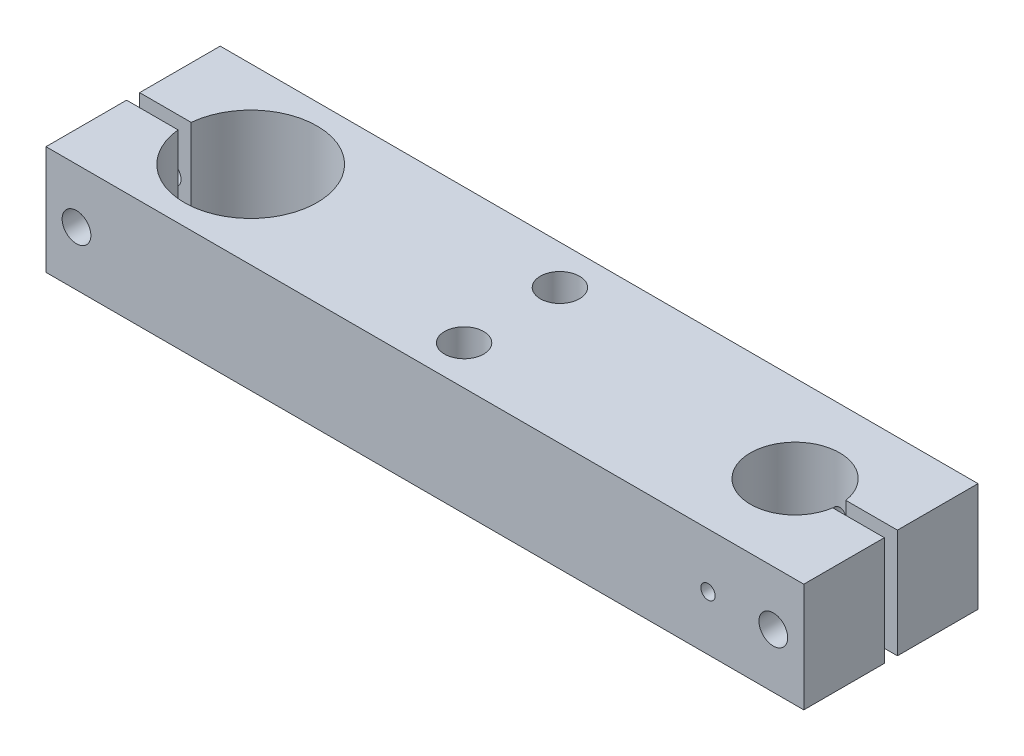
from build123d import *

# Parameters (mm, degrees)
BOSS_EXTRU_1_DEPTH   = 25
D_GAGEMENT_M61_D     = 6.6
D_GAGEMENT_M61_DEPTH = 18.5
TROU_TARAUD_M61_D    = 5
TROU_TARAUD_M41_D    = 3.3
D_GAGEMENT_M81_D     = 9


with BuildPart() as part:
    # Esquisse1 → Boss.-Extru.1 (new body)
    with BuildSketch(Plane(origin=(0, 0, 0), x_dir=(1, 0, 0), z_dir=(0, 1, 0))):
        with BuildLine():
            Line((-87, -1.5), (-87, -20))
            Line((-87, -20), (87, -20))
            Line((87, -20), (87, -1.5))
            Line((87, -1.5), (75.139649895, -1.5))
            ThreePointArc((75.139649895, -1.5), (54.75, 0), (75.139649895, 1.5))
            Line((75.139649895, 1.5), (87, 1.5))
            Line((87, 1.5), (87, 20))
            Line((87, 20), (-87, 20))
            Line((-87, 20), (-87, 1.5))
            Line((-87, 1.5), (-75.176050211, 1.5))
            ThreePointArc((-75.176050211, 1.5), (-59.249089125, 15.231501333), (-44.75, 0))
            ThreePointArc((-44.75, 0), (-59.249089125, -15.231501333), (-75.176050211, -1.5))
            Line((-75.176050211, -1.5), (-87, -1.5))
        make_face()
    extrude(amount=BOSS_EXTRU_1_DEPTH)

    # Dégagement M61
    with Locations(Plane(origin=(80, 12.5, 20), x_dir=(1, 0, 0), z_dir=(0, 0, 1))):
        with Locations((0, 0), (-160, 0)):
            Hole(D_GAGEMENT_M61_D / 2, depth=D_GAGEMENT_M61_DEPTH)

    # Trou taraudé M61 (through all)
    with Locations(Plane(origin=(80, 12.5, -1.5), x_dir=(1, 0, 0), z_dir=(0, 0, 1))):
        with Locations((0, 0), (-160, 0)):
            Hole(TROU_TARAUD_M61_D / 2)

    # Trou taraudé M41 (through all)
    with Locations(Plane(origin=(65, 12.5, 20), x_dir=(1, 0, 0), z_dir=(0, 0, 1))):
        with Locations((0, 0)):
            Hole(TROU_TARAUD_M41_D / 2)

    # Dégagement M81 (through all)
    with Locations(Plane(origin=(0, 25, -11), x_dir=(0, 0, 1), z_dir=(0, 1, 0))):
        with Locations((0, 0), (22, 0)):
            Hole(D_GAGEMENT_M81_D / 2)


solid = part.part
